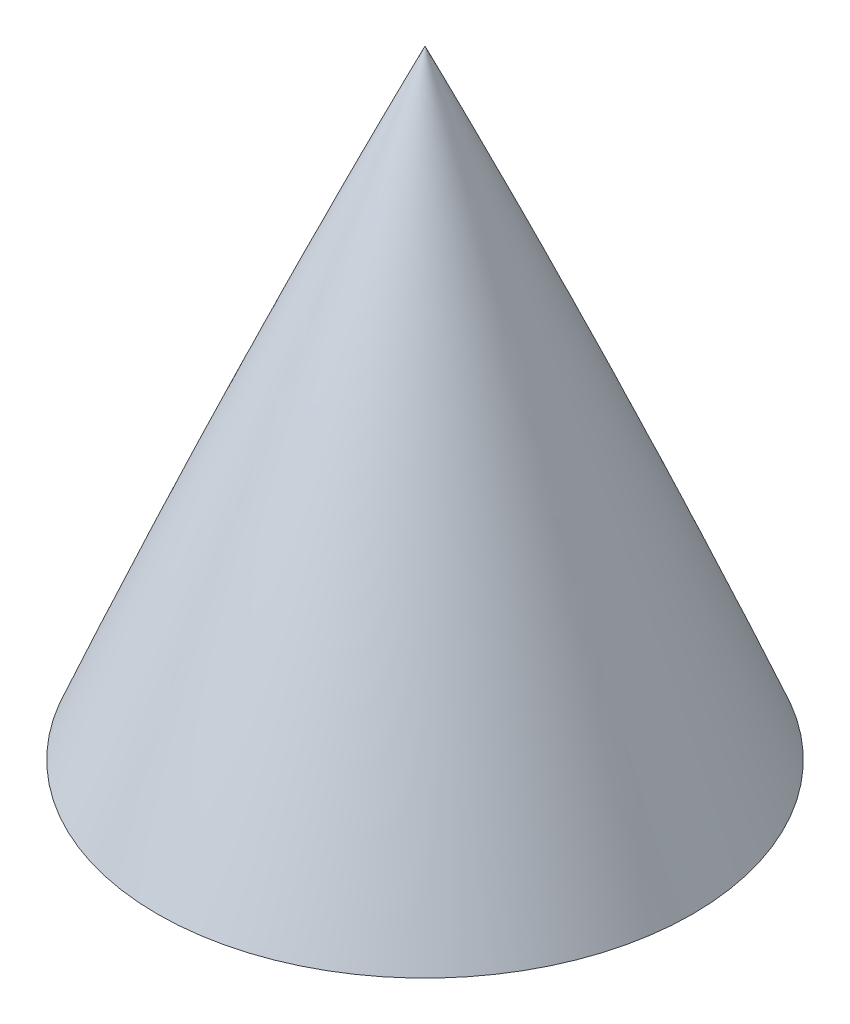
from build123d import *

# Parameters (mm, degrees)
SKETCH7_R          = 421.495799584
CUT_EXTRUDE2_DEPTH = 330.2
SKETCH8_R          = 2.413
CUT_EXTRUDE3_DEPTH = 12.7


with BuildPart() as part:
    # Sketch2 → Revolve1 (revolve)
    with BuildSketch(Plane.XY):
        with BuildLine():
            Line((-98.425, 0), (-90.551, 0))
            Line((-90.551, 0), (0, 0))
            Line((0, 0), (0, 375.92))
            Line((0, 375.92), (0, 381))
            ThreePointArc((0, 381), (-66.494117829, 194.964417939), (-98.425, 0))
        make_face()
    revolve(axis=Axis((0, 381, 0), (0, -1, 0)))

    # Sketch7 → Cut-Extrude2 (cut)
    with BuildSketch(Plane.XZ):
        with Locations((-188.314971498, 83.017725001)):
            Circle(SKETCH7_R)
    extrude(amount=-CUT_EXTRUDE2_DEPTH, mode=Mode.SUBTRACT)

    # Sketch8 → Cut-Extrude3 (cut)
    with BuildSketch(Plane(origin=(0, 330.2, 0), x_dir=(-1, 0, 0), z_dir=(0, -1, 0))):
        Circle(SKETCH8_R)
    extrude(amount=-CUT_EXTRUDE3_DEPTH, mode=Mode.SUBTRACT)


solid = part.part
